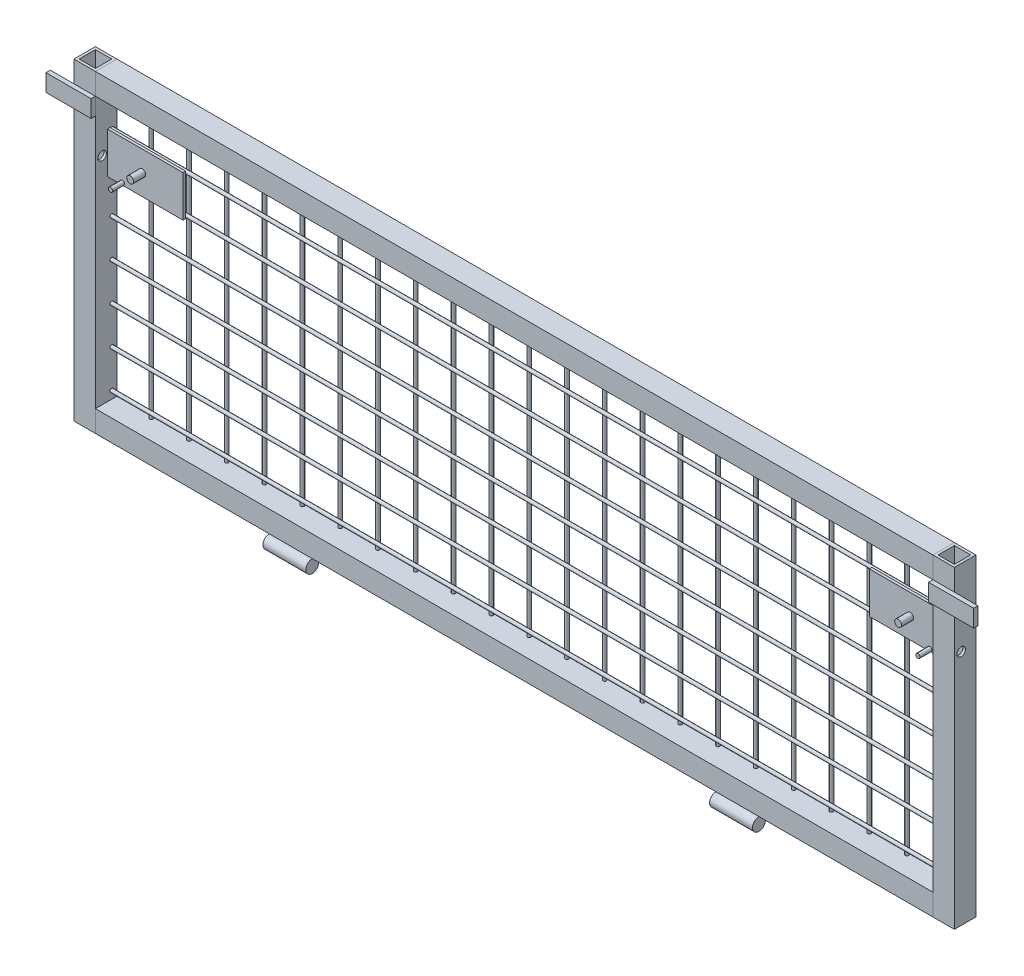
from build123d import *

# Parameters (mm, degrees)
SCHIZZO1_W                      = 25
SCHIZZO1_H                      = 25
SCHIZZO1_W_2                    = 19
SCHIZZO1_H_2                    = 19
ESTRUSIONE_ESTRUSIONE1_DEPTH    = 365
ESTRUSIONE_ESTRUSIONE1_2_DEPTH  = 365
SCHIZZO2_W                      = 25
SCHIZZO2_H                      = 25
SCHIZZO2_W_2                    = 19
SCHIZZO2_H_2                    = 19
ESTRUSIONE_ESTRUSIONE2_DEPTH    = 975
ESTRUSIONE_ESTRUSIONE2_2_DEPTH  = 975
SCHIZZO4_R                      = 7.5
ESTRUSIONE_ESTRUSIONE3_DEPTH    = 50
SCHIZZO8_W                      = 52.5
SCHIZZO8_H                      = 20
ESTRUSIONE_ESTRUSIONE8_DEPTH    = 5
SCHIZZO6_R                      = 2
ESTRUSIONE_ESTRUSIONE5_DEPTH    = 315
SCHIZZO7_R                      = 2
ESTRUSIONE_ESTRUSIONE7_DEPTH    = 975
ESTRUSIONE_ESTRUSIONE7_2_DEPTH  = 975
ESTRUSIONE_ESTRUSIONE7_3_DEPTH  = 975
ESTRUSIONE_ESTRUSIONE7_4_DEPTH  = 975
ESTRUSIONE_ESTRUSIONE7_5_DEPTH  = 975
ESTRUSIONE_ESTRUSIONE7_6_DEPTH  = 975
ESTRUSIONE_ESTRUSIONE7_7_DEPTH  = 975
TAGLIO_ESTRUSIONE1_START        = -1025
SCHIZZO9_R                      = 5
TAGLIO_ESTRUSIONE1_DEPTH        = 1025
SCHIZZO10_W                     = 88
SCHIZZO10_H                     = 48
ESTRUSIONE_ESTRUSIONE10_DEPTH   = 3
ESTRUSIONE_ESTRUSIONE10_2_DEPTH = 3
SCHIZZO11_R                     = 2.5
ESTRUSIONE_ESTRUSIONE11_DEPTH   = 14
SCHIZZO12_R                     = 4
ESTRUSIONE_ESTRUSIONE12_DEPTH   = 14


with BuildPart() as part:
    # Schizzo1 → Estrusione-Estrusione1 (new body)
    with BuildSketch(Plane(origin=(0, 0, 0), x_dir=(1, 0, 0), z_dir=(0, 1, 0))):
        with Locations((-500, 0)):
            Rectangle(SCHIZZO1_W, SCHIZZO1_H)
        with Locations((-500, 0)):
            Rectangle(SCHIZZO1_W_2, SCHIZZO1_H_2, mode=Mode.SUBTRACT)
    extrude(amount=ESTRUSIONE_ESTRUSIONE1_DEPTH)


with BuildPart() as body_2:
    # Schizzo1 → Estrusione-Estrusione1 2 (new body)
    with BuildSketch(Plane(origin=(0, 0, 0), x_dir=(1, 0, 0), z_dir=(0, 1, 0))):
        with Locations((500, 0)):
            Rectangle(SCHIZZO1_W, SCHIZZO1_H)
        with Locations((500, 0)):
            Rectangle(SCHIZZO1_W_2, SCHIZZO1_H_2, mode=Mode.SUBTRACT)
    extrude(amount=ESTRUSIONE_ESTRUSIONE1_2_DEPTH)

    # Schizzo8 → Estrusione-Estrusione8 (add)
    with BuildSketch(Plane.XY.offset(12.5)):
        with Locations((513.75, 330)):
            Rectangle(SCHIZZO8_W, SCHIZZO8_H)
        with Locations((-513.75, 330)):
            Rectangle(SCHIZZO8_W, SCHIZZO8_H)
    extrude(amount=ESTRUSIONE_ESTRUSIONE8_DEPTH)


with BuildPart() as body_3:
    # Schizzo2 → Estrusione-Estrusione2 (new body)
    with BuildSketch(Plane(origin=(-487.5, 0, 0), x_dir=(0, 0, -1), z_dir=(1, 0, 0))):
        with Locations((0, 12.5)):
            Rectangle(SCHIZZO2_W, SCHIZZO2_H)
        with Locations((0, 12.5)):
            Rectangle(SCHIZZO2_W_2, SCHIZZO2_H_2, mode=Mode.SUBTRACT)
    extrude(amount=ESTRUSIONE_ESTRUSIONE2_DEPTH)

    # Schizzo6 → Estrusione-Estrusione5 (add)
    with BuildSketch(Plane(origin=(0, 25, 0), x_dir=(1, 0, 0), z_dir=(0, 1, 0))):
        with Locations((-445.5, 10.5)):
            Circle(SCHIZZO6_R)
        with Locations((-401.5, 10.5)):
            Circle(SCHIZZO6_R)
        with Locations((-357.5, 10.5)):
            Circle(SCHIZZO6_R)
        with Locations((-313.5, 10.5)):
            Circle(SCHIZZO6_R)
        with Locations((-269.5, 10.5)):
            Circle(SCHIZZO6_R)
        with Locations((-225.5, 10.5)):
            Circle(SCHIZZO6_R)
        with Locations((-181.5, 10.5)):
            Circle(SCHIZZO6_R)
        with Locations((-137.5, 10.5)):
            Circle(SCHIZZO6_R)
        with Locations((-93.5, 10.5)):
            Circle(SCHIZZO6_R)
        with Locations((-49.5, 10.5)):
            Circle(SCHIZZO6_R)
        with Locations((-5.5, 10.5)):
            Circle(SCHIZZO6_R)
        with Locations((38.5, 10.5)):
            Circle(SCHIZZO6_R)
        with Locations((82.5, 10.5)):
            Circle(SCHIZZO6_R)
        with Locations((126.5, 10.5)):
            Circle(SCHIZZO6_R)
        with Locations((170.5, 10.5)):
            Circle(SCHIZZO6_R)
        with Locations((214.5, 10.5)):
            Circle(SCHIZZO6_R)
        with Locations((258.5, 10.5)):
            Circle(SCHIZZO6_R)
        with Locations((302.5, 10.5)):
            Circle(SCHIZZO6_R)
        with Locations((346.5, 10.5)):
            Circle(SCHIZZO6_R)
        with Locations((390.5, 10.5)):
            Circle(SCHIZZO6_R)
        with Locations((434.5, 10.5)):
            Circle(SCHIZZO6_R)
        with Locations((478.5, 10.5)):
            Circle(SCHIZZO6_R)
    extrude(amount=ESTRUSIONE_ESTRUSIONE5_DEPTH)


with BuildPart() as body_4:
    # Schizzo2 → Estrusione-Estrusione2 2 (new body)
    with BuildSketch(Plane(origin=(-487.5, 0, 0), x_dir=(0, 0, -1), z_dir=(1, 0, 0))):
        with Locations((0, 352.5)):
            Rectangle(SCHIZZO2_W, SCHIZZO2_H)
        with Locations((0, 352.5)):
            Rectangle(SCHIZZO2_W_2, SCHIZZO2_H_2, mode=Mode.SUBTRACT)
    extrude(amount=ESTRUSIONE_ESTRUSIONE2_2_DEPTH)


with BuildPart() as body_5:
    # Schizzo4 → Estrusione-Estrusione3 (new body)
    with BuildSketch(Plane(origin=(285, 0, 0), x_dir=(0, 0, -1), z_dir=(1, 0, 0))):
        with Locations((-12.5, -7.5)):
            Circle(SCHIZZO4_R)
    extrude(amount=-ESTRUSIONE_ESTRUSIONE3_DEPTH)


with BuildPart() as body_6:
    # Specchia1: mirrored copy
    add(body_5.part.mirror(Plane(origin=(0, 0, 0), x_dir=(0, 0, 1), z_dir=(1, 0, 0))))


with BuildPart() as body_7:
    # Schizzo7 → Estrusione-Estrusione7 (new body)
    with BuildSketch(Plane(origin=(-487.5, 0, 0), x_dir=(0, 0, -1), z_dir=(1, 0, 0))):
        with Locations((6.5, 298)):
            Circle(SCHIZZO7_R)
    extrude(amount=ESTRUSIONE_ESTRUSIONE7_DEPTH)


with BuildPart() as body_8:
    # Schizzo7 → Estrusione-Estrusione7 2 (new body)
    with BuildSketch(Plane(origin=(-487.5, 0, 0), x_dir=(0, 0, -1), z_dir=(1, 0, 0))):
        with Locations((6.5, 254)):
            Circle(SCHIZZO7_R)
    extrude(amount=ESTRUSIONE_ESTRUSIONE7_2_DEPTH)


with BuildPart() as body_9:
    # Schizzo7 → Estrusione-Estrusione7 3 (new body)
    with BuildSketch(Plane(origin=(-487.5, 0, 0), x_dir=(0, 0, -1), z_dir=(1, 0, 0))):
        with Locations((6.5, 210)):
            Circle(SCHIZZO7_R)
    extrude(amount=ESTRUSIONE_ESTRUSIONE7_3_DEPTH)


with BuildPart() as body_10:
    # Schizzo7 → Estrusione-Estrusione7 4 (new body)
    with BuildSketch(Plane(origin=(-487.5, 0, 0), x_dir=(0, 0, -1), z_dir=(1, 0, 0))):
        with Locations((6.5, 166)):
            Circle(SCHIZZO7_R)
    extrude(amount=ESTRUSIONE_ESTRUSIONE7_4_DEPTH)


with BuildPart() as body_11:
    # Schizzo7 → Estrusione-Estrusione7 5 (new body)
    with BuildSketch(Plane(origin=(-487.5, 0, 0), x_dir=(0, 0, -1), z_dir=(1, 0, 0))):
        with Locations((6.5, 122)):
            Circle(SCHIZZO7_R)
    extrude(amount=ESTRUSIONE_ESTRUSIONE7_5_DEPTH)


with BuildPart() as body_12:
    # Schizzo7 → Estrusione-Estrusione7 6 (new body)
    with BuildSketch(Plane(origin=(-487.5, 0, 0), x_dir=(0, 0, -1), z_dir=(1, 0, 0))):
        with Locations((6.5, 78)):
            Circle(SCHIZZO7_R)
    extrude(amount=ESTRUSIONE_ESTRUSIONE7_6_DEPTH)


with BuildPart() as body_13:
    # Schizzo7 → Estrusione-Estrusione7 7 (new body)
    with BuildSketch(Plane(origin=(-487.5, 0, 0), x_dir=(0, 0, -1), z_dir=(1, 0, 0))):
        with Locations((6.5, 34)):
            Circle(SCHIZZO7_R)
    extrude(amount=ESTRUSIONE_ESTRUSIONE7_7_DEPTH)


with BuildPart() as taglio_estrusione1_tool:
    # Schizzo9 → Taglio-Estrusione1 (new body)
    with BuildSketch(Plane.ZY.offset(512.5).offset(TAGLIO_ESTRUSIONE1_START)):
        with Locations((4.5, 276)):
            Circle(SCHIZZO9_R)
    extrude(amount=TAGLIO_ESTRUSIONE1_DEPTH)


with BuildPart() as part_1:
    add(part.part)

    # Taglio-Estrusione1: cut by taglio_estrusione1_tool
    add(taglio_estrusione1_tool.part, mode=Mode.SUBTRACT)


with BuildPart() as body_2_1:
    add(body_2.part)

    # Taglio-Estrusione1: cut by taglio_estrusione1_tool
    add(taglio_estrusione1_tool.part, mode=Mode.SUBTRACT)


with BuildPart() as body_14:
    # Schizzo10 → Estrusione-Estrusione10 (new body)
    with BuildSketch(Plane.XY.offset(-4.5)):
        with Locations((-443.5, 276)):
            Rectangle(SCHIZZO10_W, SCHIZZO10_H)
    extrude(amount=ESTRUSIONE_ESTRUSIONE10_DEPTH)

    # Schizzo11 → Estrusione-Estrusione11 (add)
    with BuildSketch(Plane.XY.offset(-1.5)):
        with Locations((-470, 254.5)):
            Circle(SCHIZZO11_R)
        with Locations((470, 254.5)):
            Circle(SCHIZZO11_R)
    extrude(amount=ESTRUSIONE_ESTRUSIONE11_DEPTH)

    # Schizzo12 → Estrusione-Estrusione12 (add)
    with BuildSketch(Plane.XY.offset(-1.5)):
        with Locations((-447, 276)):
            Circle(SCHIZZO12_R)
        with Locations((447, 276)):
            Circle(SCHIZZO12_R)
    extrude(amount=ESTRUSIONE_ESTRUSIONE12_DEPTH)


with BuildPart() as body_15:
    # Schizzo10 → Estrusione-Estrusione10 2 (new body)
    with BuildSketch(Plane.XY.offset(-4.5)):
        with Locations((443.5, 276)):
            Rectangle(SCHIZZO10_W, SCHIZZO10_H)
    extrude(amount=ESTRUSIONE_ESTRUSIONE10_2_DEPTH)


solid = Compound([body_3.part, body_4.part, body_5.part, body_6.part, body_7.part, body_8.part, body_9.part, body_10.part, body_11.part, body_12.part, body_13.part, part_1.part, body_2_1.part, body_14.part, body_15.part])
